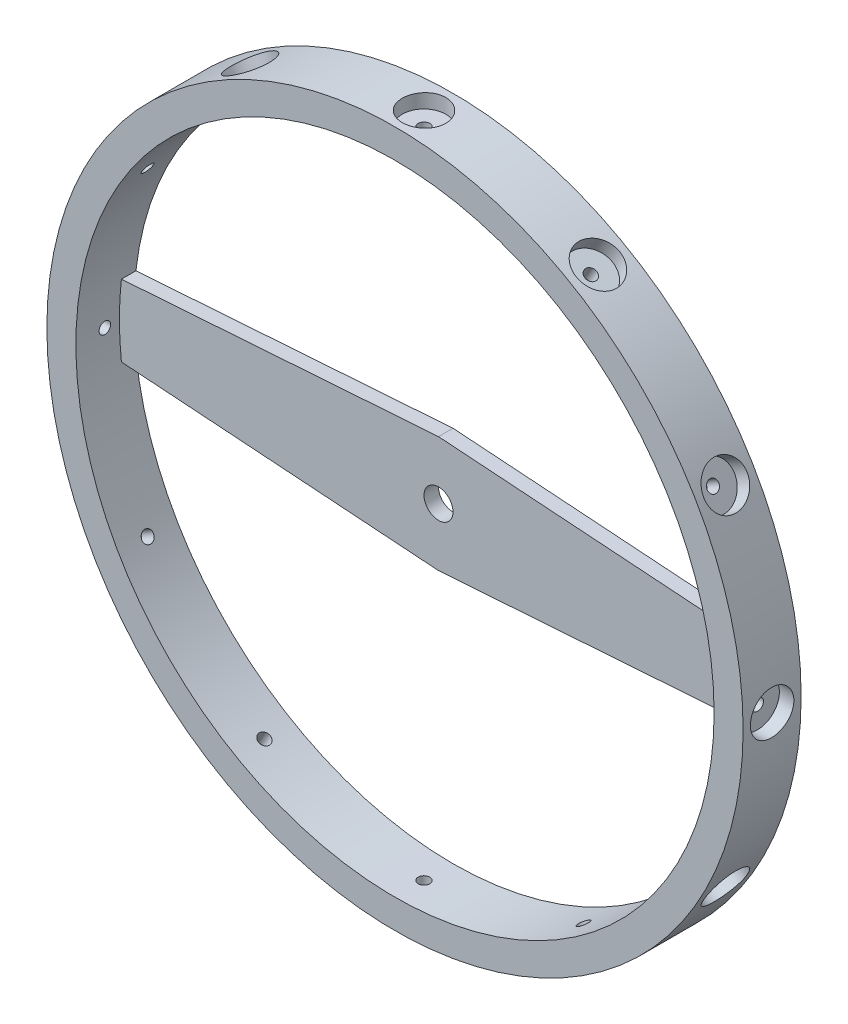
from build123d import *

# Parameters (mm, degrees)
CROQUIS1_R              = 6
CROQUIS1_R_2            = 5.5
SALIENTE_EXTRUIR1_DEPTH = 1
SALIENTE_EXTRUIR2_DEPTH = 0.25
CROQUIS8_R              = 0.1
CORTAR_EXTRUIR4_DEPTH   = 1
CROQUIS9_R              = 0.375
CORTAR_EXTRUIR5_DEPTH   = 0.25
MATRIZC7_COUNT          = 12
CROQUIS10_R             = 0.25
CORTAR_EXTRUIR6_DEPTH   = 10


with BuildPart() as part:
    # Croquis1 → Saliente-Extruir1 (new body)
    with BuildSketch(Plane.XY):
        Circle(CROQUIS1_R)
        Circle(CROQUIS1_R_2, mode=Mode.SUBTRACT)
    extrude(amount=SALIENTE_EXTRUIR1_DEPTH)

    # Croquis5 → Saliente-Extruir2 (add)
    with BuildSketch(Plane.XY):
        with BuildLine():
            Line((0, 1), (0, -1))
            Line((0, -1), (5.465187795, -0.617836841))
            ThreePointArc((5.465187795, -0.617836841), (5.5, 0), (5.465187795, 0.617836841))
            Line((5.465187795, 0.617836841), (0, 1))
        make_face()
    saliente_extruir2 = extrude(amount=SALIENTE_EXTRUIR2_DEPTH)

    # Simetría1: Saliente-Extruir2 across Right Plane
    add(saliente_extruir2.mirror(Plane(origin=(0, 0, 0), x_dir=(0, 0, -1), z_dir=(1, 0, 0))))

    # Croquis8 → Cortar-Extruir4 (cut)
    with BuildSketch(Plane(origin=(0, 6, 0), x_dir=(-1, 0, 0), z_dir=(0, 1, 0))):
        with Locations((0, 0.5)):
            Circle(CROQUIS8_R)
    cortar_extruir4 = extrude(amount=-CORTAR_EXTRUIR4_DEPTH, mode=Mode.SUBTRACT)

    # Croquis9 → Cortar-Extruir5 (cut)
    with BuildSketch(Plane(origin=(0, 6, 0), x_dir=(-1, 0, 0), z_dir=(0, 1, 0))):
        with Locations((0, 0.5)):
            Circle(CROQUIS9_R)
    cortar_extruir5 = extrude(amount=-CORTAR_EXTRUIR5_DEPTH, mode=Mode.SUBTRACT)

    # MatrizC7: Cortar-Extruir4, Cortar-Extruir5 ×12 about axis
    matrizc7_axis = Axis((0, 0, 0), (0, 0, 1))
    for i in range(1, MATRIZC7_COUNT):
        add(cortar_extruir4.rotate(matrizc7_axis, i * 360 / MATRIZC7_COUNT), mode=Mode.SUBTRACT)
        add(cortar_extruir5.rotate(matrizc7_axis, i * 360 / MATRIZC7_COUNT), mode=Mode.SUBTRACT)

    # Croquis10 → Cortar-Extruir6 (cut)
    with BuildSketch(Plane(origin=(0, 0, 0), x_dir=(-1, 0, 0), z_dir=(0, 0, -1))):
        Circle(CROQUIS10_R)
    extrude(amount=-CORTAR_EXTRUIR6_DEPTH, mode=Mode.SUBTRACT)


solid = part.part
